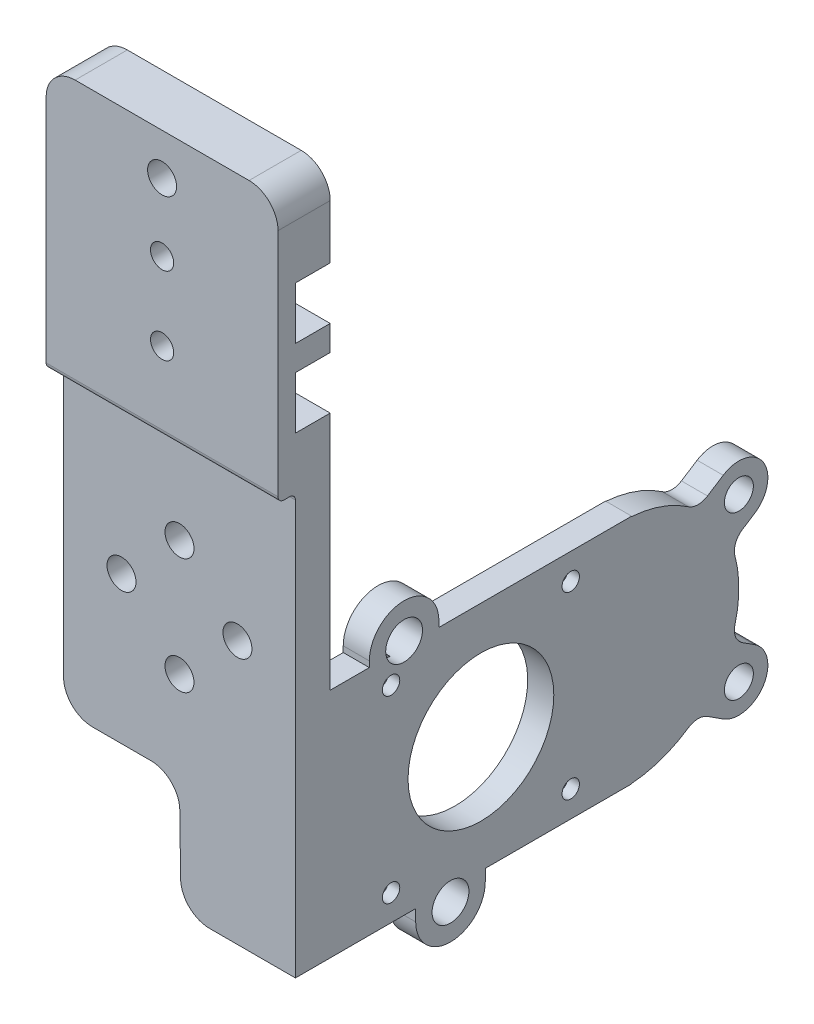
from build123d import *

# Parameters (mm, degrees)
SKETCH2_W            = 40
SKETCH2_H            = 65.4
SKETCH2_R            = 2.5
BOSS_EXTRUDE1_DEPTH  = 6
SKETCH3_W            = 4.5
SKETCH3_H            = 40
BOSS_EXTRUDE2_DEPTH  = 52
CUT_EXTRUDE1_REACH   = 6.5
SKETCH4_R            = 12.573151632
SKETCH4_R_2          = 1.5
SKETCH5_R            = 4.5
CUT_EXTRUDE2_DEPTH   = 1.5
SKETCH6_R            = 3
CUT_EXTRUDE3_DEPTH   = 2.5
FILLET1_R            = 5
SKETCH11_R           = 2.5
BOSS_EXTRUDE6_DEPTH  = 4.5
FILLET2_R            = 3
SKETCH9_R            = 3.175
BOSS_EXTRUDE15_DEPTH = 4.5
SKETCH24_R           = 3.175
CUT_EXTRUDE11_DEPTH  = 4.5
SKETCH15_R           = 3
CUT_EXTRUDE12_DEPTH  = 2.5
SKETCH25_W           = 40
SKETCH25_H           = 9
BOSS_EXTRUDE16_DEPTH = 52.75
SKETCH28_W           = 40
SKETCH28_H           = 2
CUT_EXTRUDE15_DEPTH  = 3
SKETCH33_W           = 40
SKETCH33_H           = 5
CUT_EXTRUDE18_DEPTH  = 3
FILLET7_R            = 1
FILLET8_R            = 5
SKETCH31_W           = 40
SKETCH31_H           = 9.0424
CUT_EXTRUDE16_DEPTH  = 6
SKETCH32_R           = 2
CUT_EXTRUDE17_DEPTH  = 4
SKETCH34_R           = 2.5
CUT_EXTRUDE19_DEPTH  = 9
CUT_EXTRUDE20_DEPTH  = 10
FILLET9_R            = 5


with BuildPart() as part:
    # Sketch2 → Boss-Extrude1 (new body)
    with BuildSketch(Plane.XY):
        with Locations((0, 12.7)):
            Rectangle(SKETCH2_W, SKETCH2_H)
        with Locations((0, 35.4)):
            Circle(SKETCH2_R, mode=Mode.SUBTRACT)
        with Locations((0, 15.4)):
            Circle(SKETCH2_R, mode=Mode.SUBTRACT)
        with Locations((-10, 25.4)):
            Circle(SKETCH2_R, mode=Mode.SUBTRACT)
        with Locations((10, 25.4)):
            Circle(SKETCH2_R, mode=Mode.SUBTRACT)
    extrude(amount=-BOSS_EXTRUDE1_DEPTH)

    # Sketch3 → Boss-Extrude2 (add)
    with BuildSketch(Plane(origin=(0, 0, -6), x_dir=(-1, 0, 0), z_dir=(0, 0, -1))):
        with Locations((-17.75, 0)):
            Rectangle(SKETCH3_W, SKETCH3_H)
    extrude(amount=BOSS_EXTRUDE2_DEPTH)

    # Sketch4 → Cut-Extrude1 (cut, up to next)
    with BuildSketch(Plane.ZY.offset(-15.5), mode=Mode.PRIVATE) as cut_extrude1_sk1:
        with Locations((-32, 0)):
            Circle(SKETCH4_R)
    cut_extrude1_tool1 = extrude(cut_extrude1_sk1.sketch, amount=-CUT_EXTRUDE1_REACH, mode=Mode.PRIVATE) & part.part
    add(cut_extrude1_tool1.solids().sort_by_distance((15.5, 0, -32))[0], mode=Mode.SUBTRACT)
    # Sketch4 → Cut-Extrude1 (cut, up to next)
    with BuildSketch(Plane.ZY.offset(-15.5), mode=Mode.PRIVATE) as cut_extrude1_sk2:
        with Locations((-16.5, 15.5)):
            Circle(SKETCH4_R_2)
    cut_extrude1_tool2 = extrude(cut_extrude1_sk2.sketch, amount=-CUT_EXTRUDE1_REACH, mode=Mode.PRIVATE) & part.part
    add(cut_extrude1_tool2.solids().sort_by_distance((15.5, 15.5, -16.5))[0], mode=Mode.SUBTRACT)
    # Sketch4 → Cut-Extrude1 (cut, up to next)
    with BuildSketch(Plane.ZY.offset(-15.5), mode=Mode.PRIVATE) as cut_extrude1_sk3:
        with Locations((-16.5, -15.5)):
            Circle(SKETCH4_R_2)
    cut_extrude1_tool3 = extrude(cut_extrude1_sk3.sketch, amount=-CUT_EXTRUDE1_REACH, mode=Mode.PRIVATE) & part.part
    add(cut_extrude1_tool3.solids().sort_by_distance((15.5, -15.5, -16.5))[0], mode=Mode.SUBTRACT)
    # Sketch4 → Cut-Extrude1 (cut, up to next)
    with BuildSketch(Plane.ZY.offset(-15.5), mode=Mode.PRIVATE) as cut_extrude1_sk4:
        with Locations((-47.5, -15.5)):
            Circle(SKETCH4_R_2)
    cut_extrude1_tool4 = extrude(cut_extrude1_sk4.sketch, amount=-CUT_EXTRUDE1_REACH, mode=Mode.PRIVATE) & part.part
    add(cut_extrude1_tool4.solids().sort_by_distance((15.5, -15.5, -47.5))[0], mode=Mode.SUBTRACT)
    # Sketch4 → Cut-Extrude1 (cut, up to next)
    with BuildSketch(Plane.ZY.offset(-15.5), mode=Mode.PRIVATE) as cut_extrude1_sk5:
        with Locations((-47.5, 15.5)):
            Circle(SKETCH4_R_2)
    cut_extrude1_tool5 = extrude(cut_extrude1_sk5.sketch, amount=-CUT_EXTRUDE1_REACH, mode=Mode.PRIVATE) & part.part
    add(cut_extrude1_tool5.solids().sort_by_distance((15.5, 15.5, -47.5))[0], mode=Mode.SUBTRACT)

    # Sketch5 → Cut-Extrude2 (cut)
    with BuildSketch(Plane(origin=(0, 0, -6), x_dir=(-1, 0, 0), z_dir=(0, 0, -1))):
        with Locations((0, 35.4)):
            Circle(SKETCH5_R)
        with Locations((10, 25.4)):
            Circle(SKETCH5_R)
        with Locations((0, 15.4)):
            Circle(SKETCH5_R)
        with Locations((-10, 25.4)):
            Circle(SKETCH5_R)
    extrude(amount=-CUT_EXTRUDE2_DEPTH, mode=Mode.SUBTRACT)

    # Sketch6 → Cut-Extrude3 (cut)
    with BuildSketch(Plane.ZY.offset(-15.5)):
        with Locations((-16.5, 15.5)):
            Circle(SKETCH6_R)
        with Locations((-47.5, 15.5)):
            Circle(SKETCH6_R)
        with Locations((-47.5, -15.5)):
            Circle(SKETCH6_R)
        with Locations((-16.5, -15.5)):
            Circle(SKETCH6_R)
    extrude(amount=-CUT_EXTRUDE3_DEPTH, mode=Mode.SUBTRACT)

    # Fillet1
    fillet1_edges = [part.edges().sort_by_distance(p)[0] for p in [
        (-20, -20, -3),
    ]]
    fillet(fillet1_edges, radius=FILLET1_R)

    # Sketch11 → Boss-Extrude6 (add)
    with BuildSketch(Plane.ZY.offset(-15.5)):
        with BuildLine():
            Line((-58, -19.943670675), (-58, 19.943670675))
            ThreePointArc((-58, 19.943670675), (-64.026515977, 18.5297479), (-69.332027993, 15.34076457))
            ThreePointArc((-69.332027993, 15.34076457), (-72.76360296, 11.640241353), (-75.159610133, 7.198538025))
            ThreePointArc((-75.159610133, 7.198538025), (-76.5, 0), (-75.159610133, -7.198538025))
            ThreePointArc((-75.159610133, -7.198538025), (-72.76360296, -11.640241353), (-69.332027993, -15.34076457))
            ThreePointArc((-69.332027993, -15.34076457), (-64.026515977, -18.5297479), (-58, -19.943670675))
        make_face()
        with BuildLine():
            ThreePointArc((-75.159610133, 7.198538025), (-72.76360296, 11.640241353), (-69.332027993, 15.34076457))
            Line((-69.332027993, 15.34076457), (-73.799349609, 18.20790773))
            ThreePointArc((-73.799349609, 18.20790773), (-80.70790773, 16.700650391), (-79.200650391, 9.79209227))
            Line((-79.200650391, 9.79209227), (-75.159610133, 7.198538025))
        make_face()
        with Locations((-76.5, 14)):
            Circle(SKETCH11_R, mode=Mode.SUBTRACT)
        with BuildLine():
            Line((-73.799349609, -18.20790773), (-69.332027993, -15.34076457))
            ThreePointArc((-69.332027993, -15.34076457), (-72.76360296, -11.640241353), (-75.159610133, -7.198538025))
            Line((-75.159610133, -7.198538025), (-79.200650391, -9.79209227))
            ThreePointArc((-79.200650391, -9.79209227), (-80.70790773, -16.700650391), (-73.799349609, -18.20790773))
        make_face()
        with Locations((-76.5, -14)):
            Circle(SKETCH11_R, mode=Mode.SUBTRACT)
    extrude(amount=-BOSS_EXTRUDE6_DEPTH)

    # Fillet2
    fillet2_edges = [part.edges().sort_by_distance(p)[0] for p in [
        (17.75, -15.34076457, -69.332027993),
        (17.75, -7.198538025, -75.159610133),
        (17.75, 7.198538025, -75.159610133),
        (17.75, 15.34076457, -69.332027993),
    ]]
    fillet(fillet2_edges, radius=FILLET2_R)

    # Sketch9 → Boss-Extrude15 (add)
    with BuildSketch(Plane.ZY.offset(-15.5)):
        with BuildLine():
            Line((-32.75, -22), (-32.75, -18.434411342))
            Line((-32.75, -18.434411342), (-20.75, -18.434411342))
            Line((-20.75, -18.434411342), (-20.75, -22))
            ThreePointArc((-20.75, -22), (-26.75, -28), (-32.75, -22))
        make_face()
        with Locations((-26.75, -22)):
            Circle(SKETCH9_R, mode=Mode.SUBTRACT)
        with BuildLine():
            Line((-24.75, 21), (-24.75, 17.603718698))
            Line((-24.75, 17.603718698), (-12.75, 17.603718698))
            Line((-12.75, 17.603718698), (-12.75, 21))
            ThreePointArc((-12.75, 21), (-18.75, 27), (-24.75, 21))
        make_face()
        with Locations((-18.75, 21)):
            Circle(SKETCH9_R, mode=Mode.SUBTRACT)
    extrude(amount=-BOSS_EXTRUDE15_DEPTH)

    # Sketch24 → Cut-Extrude11 (cut)
    with BuildSketch(Plane.ZY.offset(-15.5)):
        with Locations((-18.75, 21)):
            Circle(SKETCH24_R)
        with Locations((-26.75, -22)):
            Circle(SKETCH24_R)
    extrude(amount=-CUT_EXTRUDE11_DEPTH, mode=Mode.SUBTRACT)

    # Sketch15 → Cut-Extrude12 (cut)
    with BuildSketch(Plane.ZY.offset(-15.5)):
        with Locations((-16.5, 15.5)):
            Circle(SKETCH15_R)
    extrude(amount=-CUT_EXTRUDE12_DEPTH, mode=Mode.SUBTRACT)

    # Sketch25 → Boss-Extrude16 (add)
    with BuildSketch(Plane(origin=(0, 45.4, 0), x_dir=(1, 0, 0), z_dir=(0, 1, 0))):
        with Locations((0, 1.5)):
            Rectangle(SKETCH25_W, SKETCH25_H)
    extrude(amount=BOSS_EXTRUDE16_DEPTH)

    # Sketch28 → Cut-Extrude15 (cut)
    with BuildSketch(Plane.XY.offset(3)):
        with Locations((0, 46.4)):
            Rectangle(SKETCH28_W, SKETCH28_H)
    extrude(amount=-CUT_EXTRUDE15_DEPTH, mode=Mode.SUBTRACT)

    # Sketch33 → Cut-Extrude18 (cut)
    with BuildSketch(Plane.XY.offset(3)):
        with Locations((0, 49.9)):
            Rectangle(SKETCH33_W, SKETCH33_H)
    extrude(amount=-CUT_EXTRUDE18_DEPTH, mode=Mode.SUBTRACT)

    # Fillet7
    fillet7_edges = [part.edges().sort_by_distance(p)[0] for p in [
        (0, 52.4, 3),
        (0, 52.4, 0),
    ]]
    fillet(fillet7_edges, radius=FILLET7_R)

    # Fillet8
    fillet8_edges = [part.edges().sort_by_distance(p)[0] for p in [
        (20, 98.15, -1.5),
        (-20, 98.15, -1.5),
    ]]
    fillet(fillet8_edges, radius=FILLET8_R)

    # Sketch31 → Cut-Extrude16 (cut)
    with BuildSketch(Plane(origin=(0, 0, -6), x_dir=(-1, 0, 0), z_dir=(0, 0, -1))):
        with Locations((0, 65.9212)):
            Rectangle(SKETCH31_W, SKETCH31_H)
        with Locations((0, 79.3136)):
            Rectangle(SKETCH31_W, SKETCH31_H)
    extrude(amount=-CUT_EXTRUDE16_DEPTH, mode=Mode.SUBTRACT)

    # Sketch32 → Cut-Extrude17 (cut, through all)
    with BuildSketch(Plane(origin=(0, 0, 0), x_dir=(-1, 0, 0), z_dir=(0, 0, -1))):
        with Locations((0, 79.3136)):
            Circle(SKETCH32_R)
        with Locations((0, 65.9212)):
            Circle(SKETCH32_R)
    extrude(amount=-CUT_EXTRUDE17_DEPTH, mode=Mode.SUBTRACT)

    # Sketch34 → Cut-Extrude19 (cut)
    with BuildSketch(Plane(origin=(0, 0, -6), x_dir=(-1, 0, 0), z_dir=(0, 0, -1))):
        with Locations((0, 90.9924)):
            Circle(SKETCH34_R)
    extrude(amount=-CUT_EXTRUDE19_DEPTH, mode=Mode.SUBTRACT)

    # Sketch35 → Cut-Extrude20 (cut)
    with BuildSketch(Plane(origin=(0, 0, -6), x_dir=(-1, 0, 0), z_dir=(0, 0, -1))):
        Polygon((-0.25, -20), (0, 0), (20, 0), (20, -20), align=None)
    extrude(amount=-CUT_EXTRUDE20_DEPTH, mode=Mode.SUBTRACT)

    # Fillet9
    fillet9_edges = [part.edges().sort_by_distance(p)[0] for p in [
        (0.25, -20, -3),
        (0, 0, -3),
        (-20, 0, -3),
    ]]
    fillet(fillet9_edges, radius=FILLET9_R)


solid = part.part
